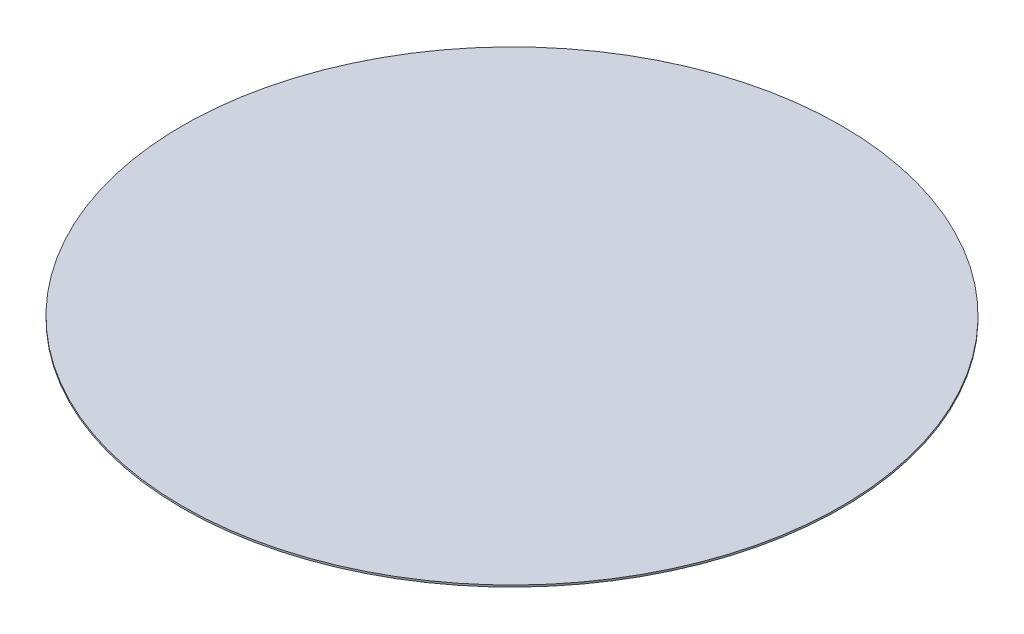
from build123d import *

# Parameters (mm, degrees)
CROQUIS1_R              = 550
SALIENTE_EXTRUIR1_DEPTH = 3


with BuildPart() as part:
    # Croquis1 → Saliente-Extruir1 (new body)
    with BuildSketch(Plane(origin=(0, 0, 0), x_dir=(1, 0, 0), z_dir=(0, 1, 0))):
        Circle(CROQUIS1_R)
    extrude(amount=SALIENTE_EXTRUIR1_DEPTH)


solid = part.part
